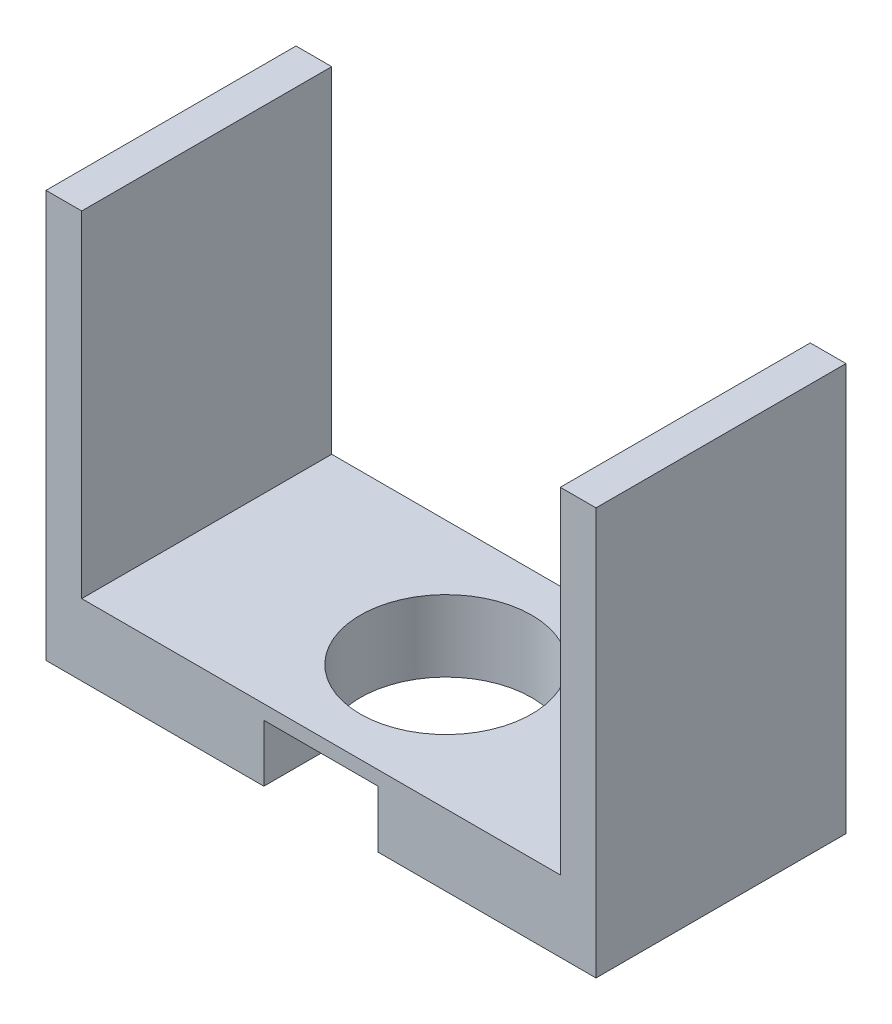
from build123d import *

# Parameters (mm, degrees)
EXTRUSION1_DEPTH = 35
ESQUISSE2_R      = 12
EXTRUSION2_DEPTH = 58
EXTRUSION3_DEPTH = 8


with BuildPart() as part:
    # Esquisse1 → Extrusion1 (new body)
    with BuildSketch(Plane.XY):
        Polygon((72, -57), (72, 0), (67, 0), (67, -47), (0, -47), (0, 0), (-5, 0), (-5, -57), align=None)
    extrude(amount=EXTRUSION1_DEPTH)

    # Esquisse2 → Extrusion2 (cut, through all)
    with BuildSketch(Plane.XZ.offset(57)):
        with Locations((33.5, 17.5)):
            Circle(ESQUISSE2_R)
    extrude(amount=-EXTRUSION2_DEPTH, mode=Mode.SUBTRACT)

    # Esquisse3 → Extrusion3 (cut)
    with BuildSketch(Plane.XZ.offset(57)):
        with BuildLine():
            Line((41.5, 26.44427191), (41.5, 35))
            Line((41.5, 35), (25.5, 35))
            Line((25.5, 35), (25.5, 26.44427191))
            ThreePointArc((25.5, 26.44427191), (33.5, 29.5), (41.5, 26.44427191))
        make_face()
    extrude(amount=-EXTRUSION3_DEPTH, mode=Mode.SUBTRACT)


solid = part.part
